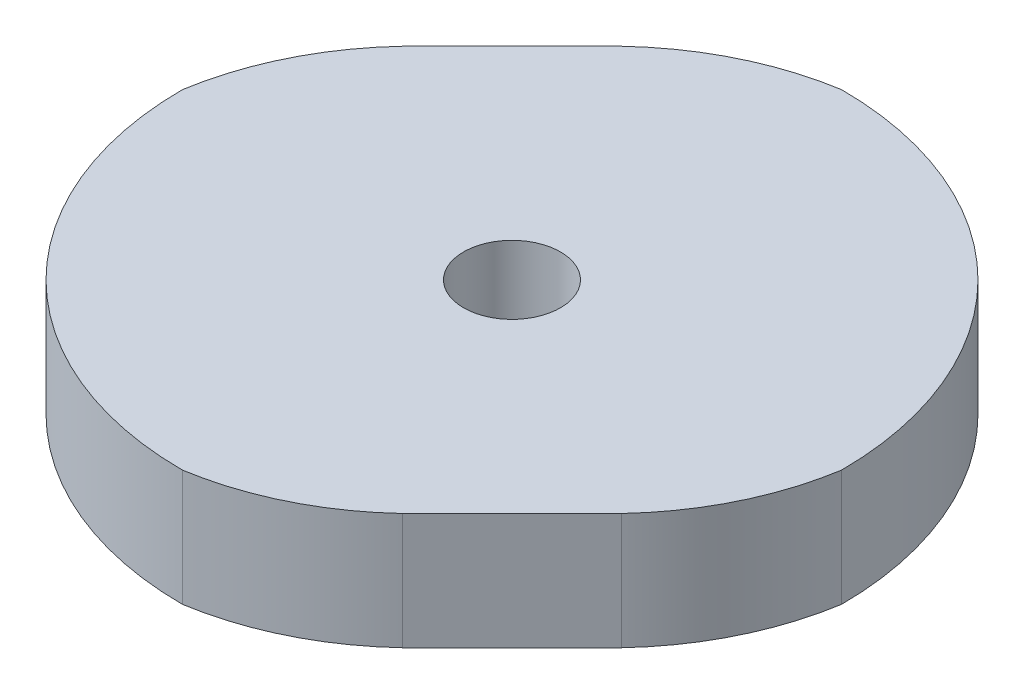
from build123d import *

# Parameters (mm, degrees)
SKETCH1_R           = 1.25
BOSS_EXTRUDE1_DEPTH = 3


with BuildPart() as part:
    # Sketch1 → Boss-Extrude1 (new body)
    with BuildSketch(Plane(origin=(0, 0, 0), x_dir=(1, 0, 0), z_dir=(0, 1, 0))):
        with BuildLine():
            Line((6.30223182, -4.135535586), (6.632271605, -3.805495802))
            ThreePointArc((6.632271605, -3.805495802), (7.850711529, -2.042416999), (8.5, 0))
            ThreePointArc((8.5, 0), (6.01040764, 6.01040764), (0, 8.5))
            ThreePointArc((0, 8.5), (-2.042416999, 7.850711529), (-3.805495802, 6.632271605))
            Line((-3.805495802, 6.632271605), (-4.135535586, 6.30223182))
            Line((-4.135535586, 6.30223182), (-6.30223182, 4.135535586))
            Line((-6.30223182, 4.135535586), (-6.632271605, 3.805495802))
            ThreePointArc((-6.632271605, 3.805495802), (-7.850711529, 2.042416999), (-8.5, 0))
            ThreePointArc((-8.5, 0), (-6.01040764, -6.01040764), (0, -8.5))
            ThreePointArc((0, -8.5), (2.042416999, -7.850711529), (3.805495802, -6.632271605))
            Line((3.805495802, -6.632271605), (4.135535586, -6.30223182))
            Line((4.135535586, -6.30223182), (6.30223182, -4.135535586))
        make_face()
        Circle(SKETCH1_R, mode=Mode.SUBTRACT)
    extrude(amount=BOSS_EXTRUDE1_DEPTH)


solid = part.part
